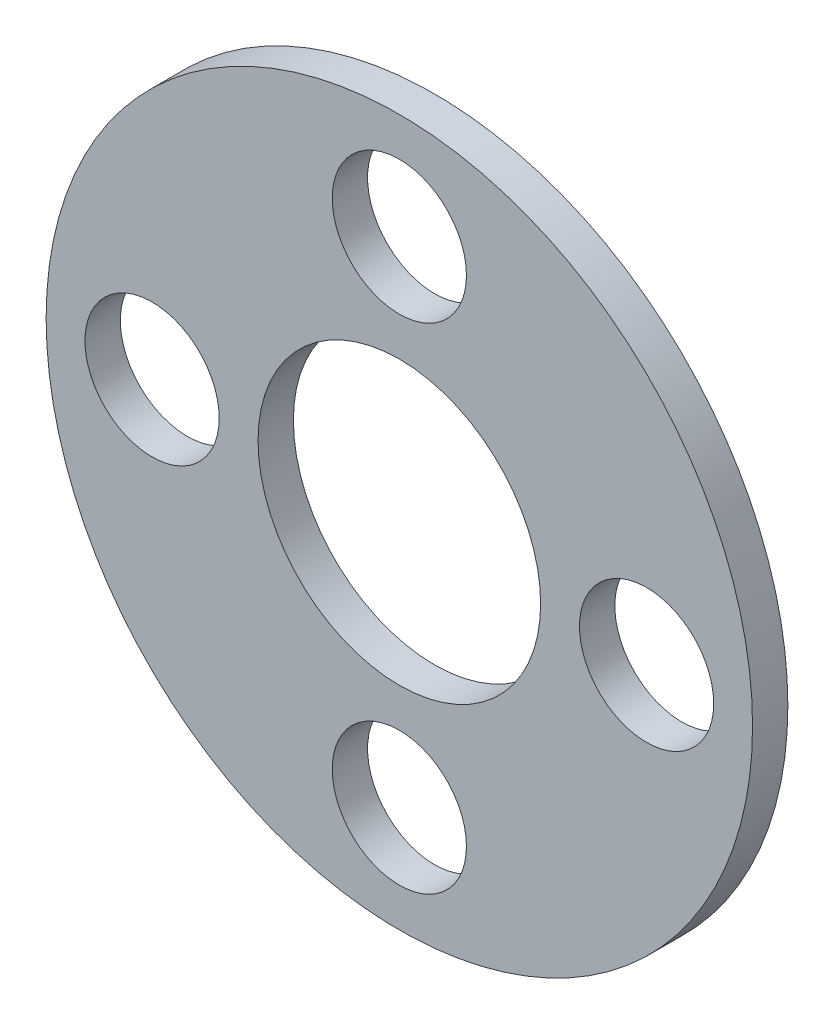
from build123d import *

# Parameters (mm, degrees)
ESQUISSE1_R                  = 10
ESQUISSE1_R_2                = 4
BOSS_EXTRU_1_DEPTH           = 1
ESQUISSE2_R                  = 1.9
ENL_V_MAT_EXTRU_1_DEPTH      = 1
ENL_V_MAT_EXTRU_1_DEPTH_BACK = 2


with BuildPart() as part:
    # Esquisse1 → Boss.-Extru.1 (new body)
    with BuildSketch(Plane.XY):
        Circle(ESQUISSE1_R)
        Circle(ESQUISSE1_R_2, mode=Mode.SUBTRACT)
    extrude(amount=BOSS_EXTRU_1_DEPTH)

    # Esquisse2 → Enlèv. mat.-Extru.1 (cut, two sides)
    with BuildSketch(Plane.XY.offset(1)) as enl_v_mat_extru_1_sk:
        with Locations((7, 0)):
            Circle(ESQUISSE2_R)
        with Locations((0, -7)):
            Circle(ESQUISSE2_R)
        with Locations((-7, 0)):
            Circle(ESQUISSE2_R)
        with Locations((0, 7)):
            Circle(ESQUISSE2_R)
    extrude(amount=ENL_V_MAT_EXTRU_1_DEPTH, mode=Mode.SUBTRACT)
    extrude(enl_v_mat_extru_1_sk.sketch, amount=-ENL_V_MAT_EXTRU_1_DEPTH_BACK, mode=Mode.SUBTRACT)


solid = part.part
